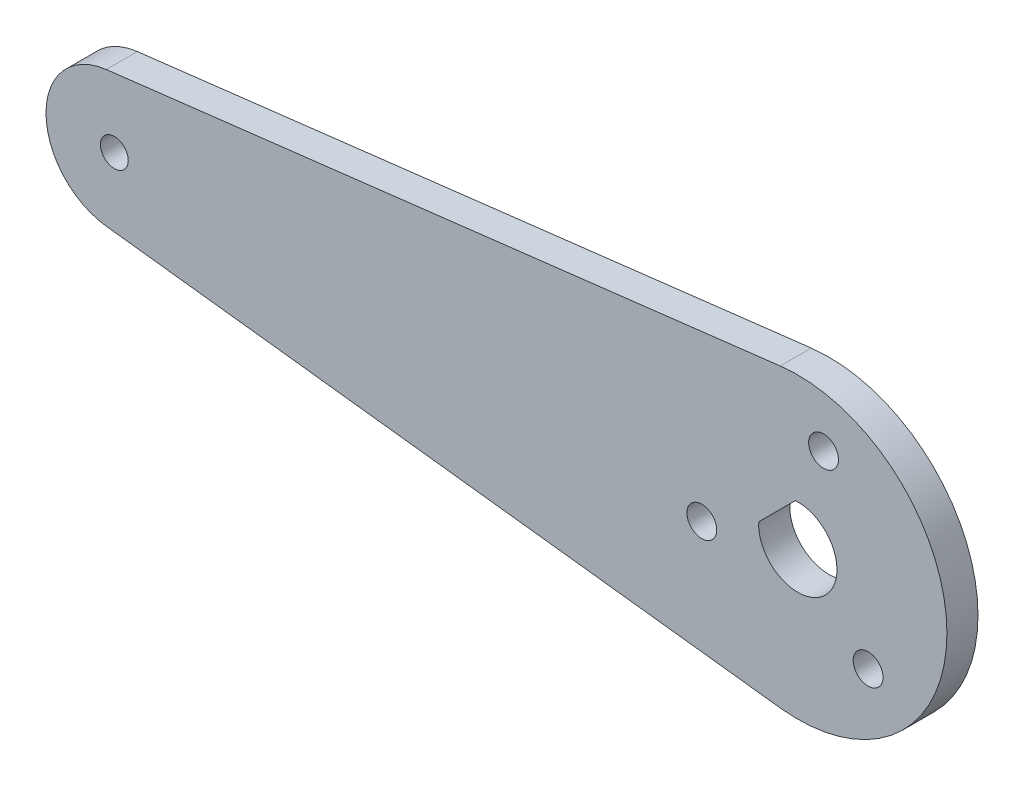
from build123d import *

# Parameters (mm, degrees)
SKETCH1_R           = 1.4224
SKETCH1_R_2         = 1.524
BOSS_EXTRUDE1_DEPTH = 3.175


with BuildPart() as part:
    # Sketch1 → Boss-Extrude1 (new body)
    with BuildSketch(Plane.XY):
        with BuildLine():
            Line((-70.6755, 6.936048929), (-1.801090909, 15.133197664))
            ThreePointArc((-1.801090909, 15.133197664), (15.24, 0), (-1.801090909, -15.133197664))
            Line((-1.801090909, -15.133197664), (-70.6755, -6.936048929))
            ThreePointArc((-70.6755, -6.936048929), (-76.835, 0), (-70.6755, 6.936048929))
        make_face()
        with Locations((-69.85, 0)):
            Circle(SKETCH1_R, mode=Mode.SUBTRACT)
        with Locations((7.184204897, -7.184204897)):
            Circle(SKETCH1_R_2, mode=Mode.SUBTRACT)
        with Locations((-9.813806395, -2.629601498)):
            Circle(SKETCH1_R_2, mode=Mode.SUBTRACT)
        with Locations((2.629601498, 9.813806395)):
            Circle(SKETCH1_R_2, mode=Mode.SUBTRACT)
        with BuildLine():
            Line((-0.25049165, 3.992149037), (-3.992149037, 0.25049165))
            ThreePointArc((-3.992149037, 0.25049165), (2.828427125, -2.828427125), (-0.25049165, 3.992149037))
        make_face(mode=Mode.SUBTRACT)
    extrude(amount=BOSS_EXTRUDE1_DEPTH)


solid = part.part
